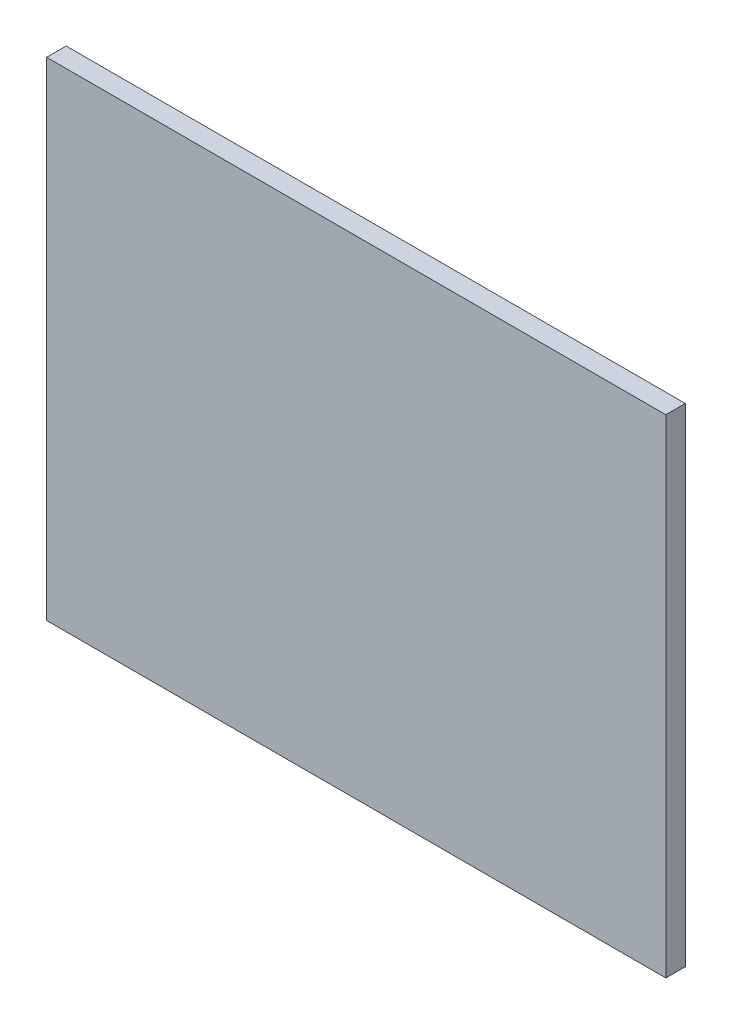
from build123d import *

# Parameters (mm, degrees)
SKIZZE1_W                       = 603
SKIZZE1_H                       = 475
AUFSATZ_LINEAR_AUSTRAGEN1_DEPTH = 19


with BuildPart() as part:
    # Skizze1 → Aufsatz-Linear austragen1 (new body)
    with BuildSketch(Plane.XY):
        Rectangle(SKIZZE1_W, SKIZZE1_H)
    extrude(amount=AUFSATZ_LINEAR_AUSTRAGEN1_DEPTH)


solid = part.part
